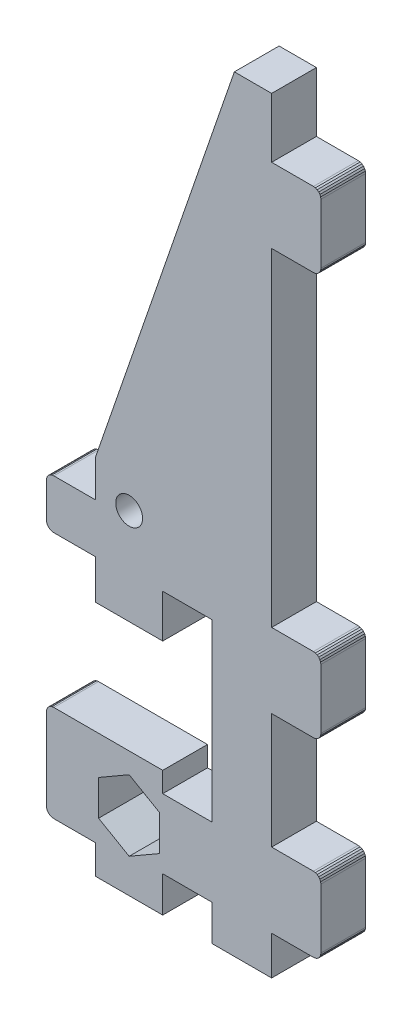
from build123d import *

# Parameters (mm, degrees)
MODEL_R                  = 1.8
RESSALTO_EXTRUS_O1_DEPTH = 6


with BuildPart() as part:
    # Model → Ressalto-extrusão1 (new body)
    with BuildSketch(Plane.XY):
        Polygon((64.544232036, 102.085333217), (58.944232036, 102.085333217), (58.944232036, 110.085333217), (53.944232036, 110.085333217), (35.344232036, 56.085333217), (35.344232036, 51.085333217), (29.744232036, 51.085333217), (29.485412991, 51.051259043), (29.244232036, 50.95135862), (29.037125255, 50.792439998), (28.878206632, 50.585333217), (28.77830621, 50.344152262), (28.744232036, 50.085333217), (28.744232036, 45.485333217), (28.77830621, 45.226514172), (28.878206632, 44.985333217), (29.037125255, 44.778226435), (29.244232036, 44.619307813), (29.485412991, 44.51940739), (29.744232036, 44.485333217), (35.344232036, 44.485333217), (35.344232036, 39.202796806), (44.344232036, 39.202796806), (44.344232036, 44.985333217), (50.944232036, 44.985333217), (50.944232036, 21.485333217), (44.344232036, 21.485333217), (44.344232036, 24.197608641), (29.744232036, 24.197608641), (29.485412991, 24.163534467), (29.244232036, 24.063634044), (29.037125255, 23.904715422), (28.878206632, 23.697608641), (28.77830621, 23.456427686), (28.744232036, 23.197608641), (28.744232036, 12.285333217), (28.77830621, 12.026514172), (28.878206632, 11.785333217), (29.037125255, 11.578226435), (29.244232036, 11.419307813), (29.485412991, 11.31940739), (29.744232036, 11.285333217), (35.344232036, 11.285333217), (35.344232036, 7.387063336), (44.340453402, 7.387063336), (44.344232036, 12.190525094), (50.944232036, 12.185333217), (50.940455526, 7.387063336), (58.944232036, 7.387063336), (58.944232036, 12.585333217), (64.544232036, 12.585333217), (64.803051081, 12.61940739), (65.044232036, 12.719307813), (65.251338817, 12.878226435), (65.41025744, 13.085333217), (65.510157862, 13.326514172), (65.544232036, 13.585333217), (65.544232036, 21.585333217), (65.510157862, 21.844152262), (65.41025744, 22.085333217), (65.251338817, 22.292439998), (65.044232036, 22.45135862), (64.803051081, 22.551259043), (64.544232036, 22.585333217), (58.944232036, 22.585333217), (58.944232036, 38.085333217), (64.544232036, 38.085333217), (64.803051081, 38.11940739), (65.044232036, 38.219307813), (65.251338817, 38.378226435), (65.41025744, 38.585333217), (65.510157862, 38.826514172), (65.544232036, 39.085333217), (65.544232036, 47.085333217), (65.510157862, 47.344152262), (65.41025744, 47.585333217), (65.251338817, 47.792439998), (65.044232036, 47.95135862), (64.803051081, 48.051259043), (64.544232036, 48.085333217), (58.944232036, 48.085333217), (58.944232036, 92.085333217), (64.544232036, 92.085333217), (64.803051081, 92.11940739), (65.044232036, 92.219307813), (65.251338817, 92.378226435), (65.41025744, 92.585333217), (65.510157862, 92.826514172), (65.544232036, 93.085333217), (65.544232036, 101.085333217), (65.510157862, 101.344152262), (65.41025744, 101.585333217), (65.251338817, 101.792439998), (65.044232036, 101.95135862), (64.803051081, 102.051259043), align=None)
        with Locations((39.844232036, 52.085333217)):
            Circle(MODEL_R, mode=Mode.SUBTRACT)
        Polygon((43.944232036, 19.069932909), (39.844232036, 21.437069013), (35.744232036, 19.069932909), (35.744232036, 14.335660702), (39.844232036, 11.968524598), (43.944232036, 14.335660702), align=None, mode=Mode.SUBTRACT)
    extrude(amount=RESSALTO_EXTRUS_O1_DEPTH)


solid = part.part
